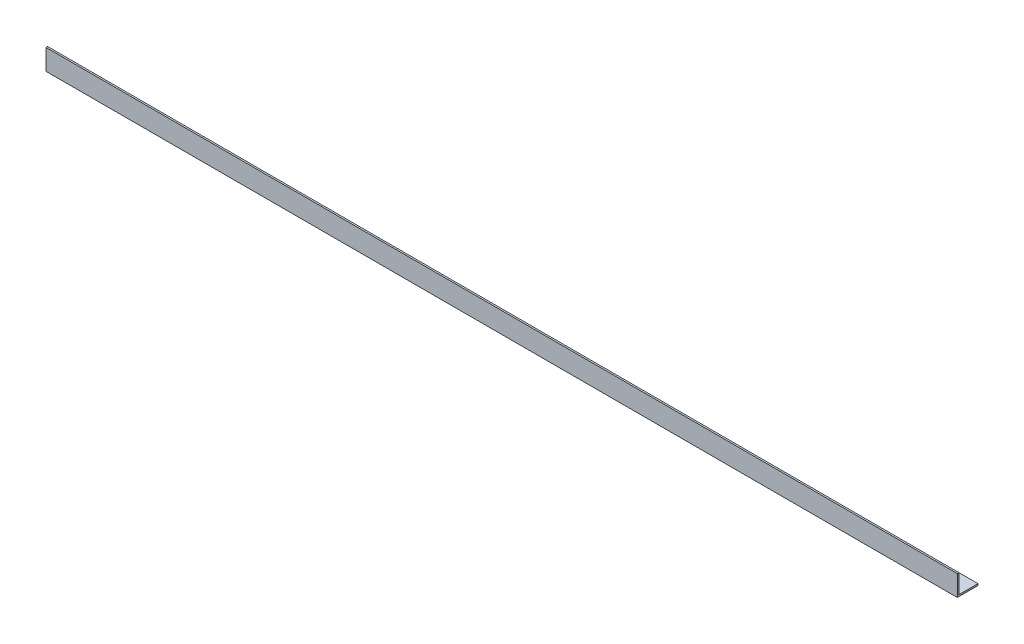
from build123d import *

# Parameters (mm, degrees)
EXTRUDE_1_DEPTH = 1660


with BuildPart() as part:
    # Эскиз1 → Вытянуть-Тонкостенный1 (new body)
    with BuildSketch(Plane(origin=(0, 0, 0), x_dir=(0, 0, -1), z_dir=(1, 0, 0))):
        Polygon((0, 37.7), (0, 0), (37.7, 0), (37.7, 3), (3, 3), (3, 37.7), align=None)
    extrude(amount=EXTRUDE_1_DEPTH)


solid = part.part
